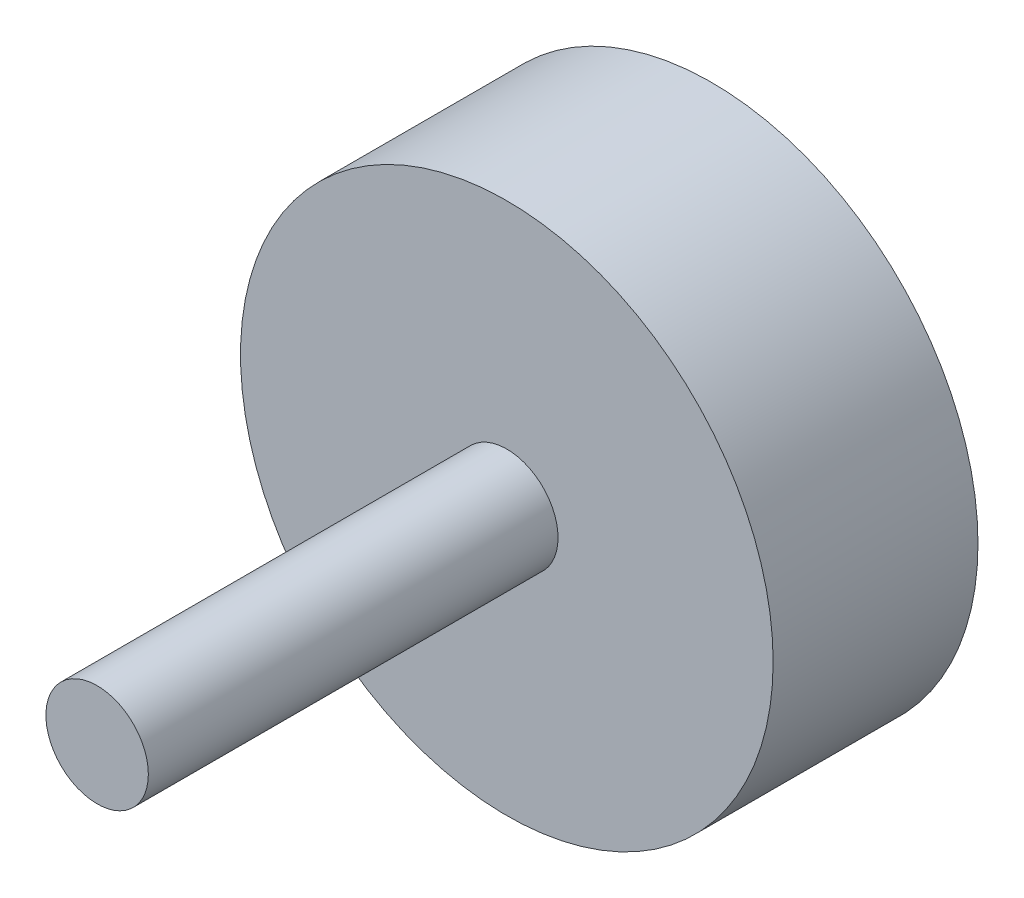
from build123d import *

# Parameters (mm, degrees)
SKETCH1_R           = 26
BOSS_EXTRUDE1_DEPTH = 20
SKETCH2_R           = 5
BOSS_EXTRUDE2_DEPTH = 40


with BuildPart() as part:
    # Sketch1 → Boss-Extrude1 (new body)
    with BuildSketch(Plane.XY):
        Circle(SKETCH1_R)
    extrude(amount=BOSS_EXTRUDE1_DEPTH)

    # Sketch2 → Boss-Extrude2 (add)
    with BuildSketch(Plane.XY.offset(20)):
        Circle(SKETCH2_R)
    extrude(amount=BOSS_EXTRUDE2_DEPTH)


solid = part.part
